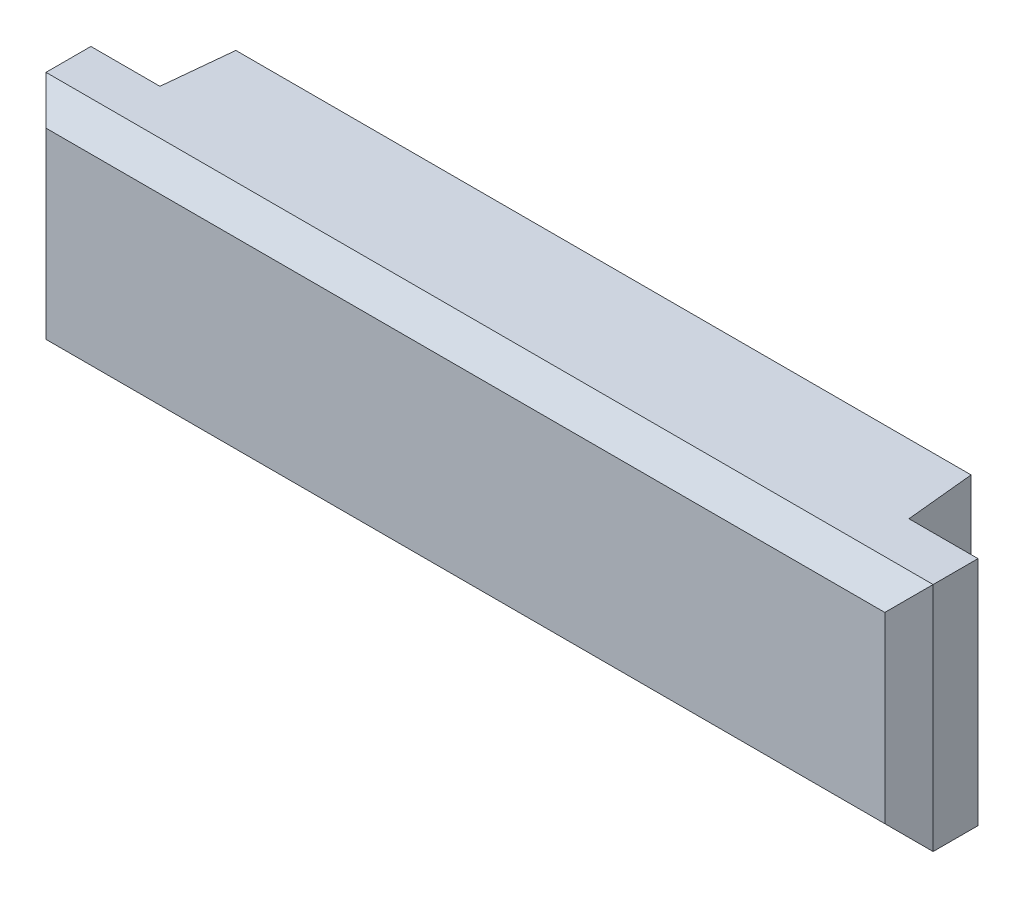
from build123d import *

# Parameters (mm, degrees)
SKETCH2_W           = 21.7
SKETCH2_H           = 4.7
SKETCH1_W           = 21.3
SKETCH1_H           = 4.7
SKETCH3_W           = 25.7
SKETCH3_H           = 6.7
BOSS_EXTRUDE1_DEPTH = 2
CHAMFER1_SIZE       = 0.7


with BuildPart() as part:
    # Sketch2 → Loft1 section 0
    with BuildSketch(Plane.XY.offset(2)):
        Rectangle(SKETCH2_W, SKETCH2_H)
    # Sketch1 → Loft1 section 1
    with BuildSketch(Plane.XY):
        Rectangle(SKETCH1_W, SKETCH1_H)
    loft()

    # Sketch3 → Boss-Extrude1 (add)
    with BuildSketch(Plane.XY.offset(2)):
        with Locations((0, -1)):
            Rectangle(SKETCH3_W, SKETCH3_H)
    extrude(amount=BOSS_EXTRUDE1_DEPTH)

    # Chamfer1
    chamfer1_edges = [part.edges().sort_by_distance(p)[0] for p in [
        (-12.85, -1, 4),
        (0, -4.35, 4),
        (12.85, -1, 4),
        (0, 2.35, 4),
    ]]
    chamfer(chamfer1_edges, length=CHAMFER1_SIZE)


solid = part.part
